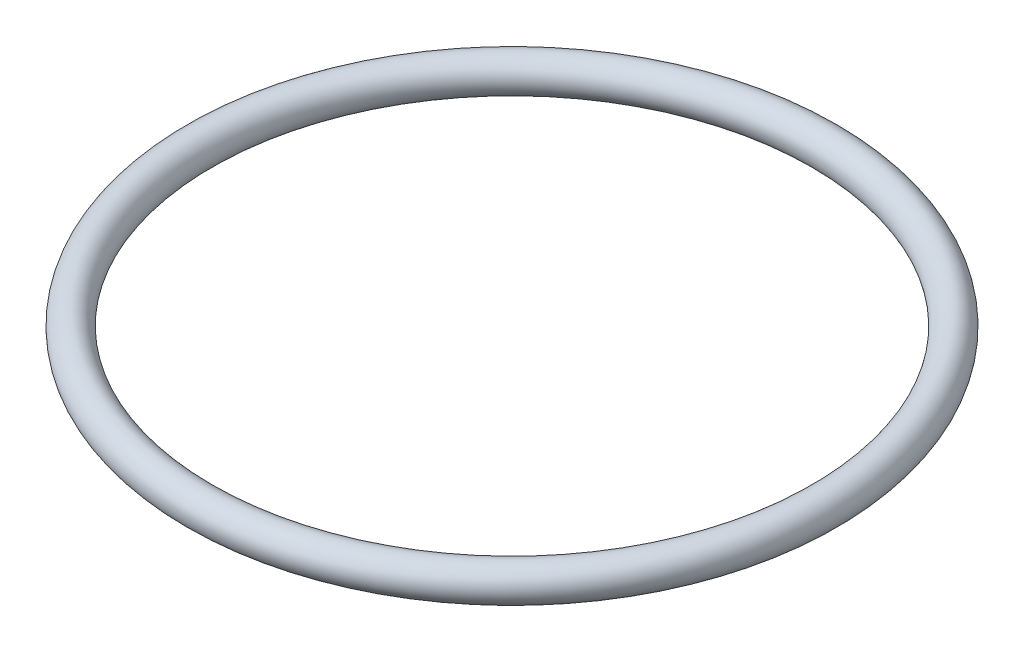
from build123d import *

# Parameters (mm, degrees)
SKETCH_1_R = 1.775


with BuildPart() as part:
    # 草图1 → 旋转1 (revolve)
    with BuildSketch(Plane.XY):
        with Locations((31.775, 1.678692747)):
            Circle(SKETCH_1_R)
    revolve(axis=Axis((0, 55, 0), (0, -1, 0)))


solid = part.part
